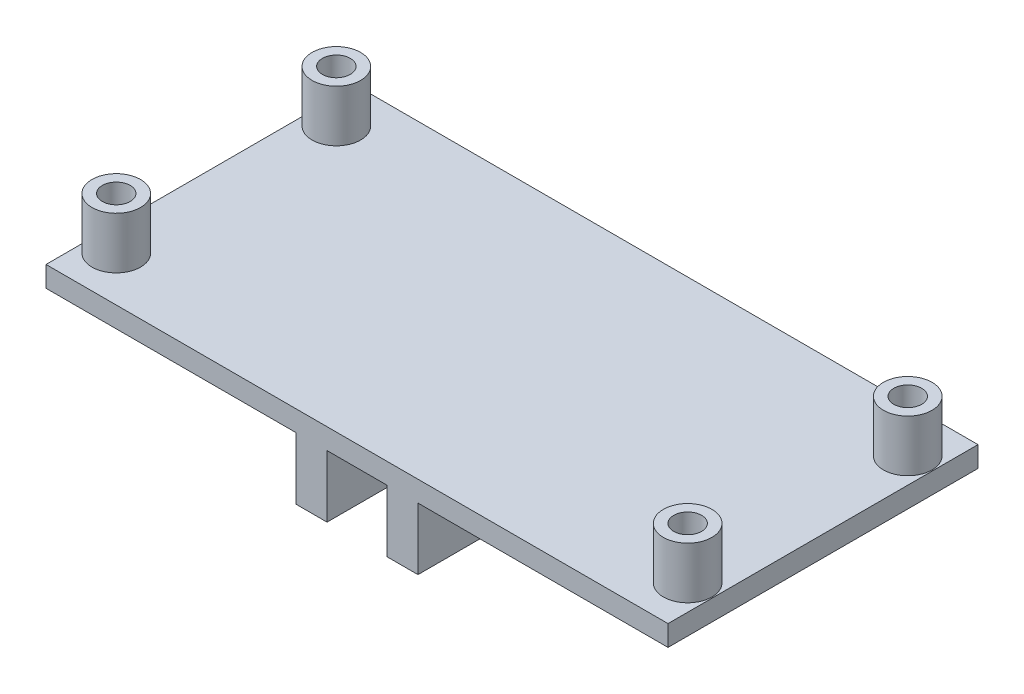
from build123d import *

# Parameters (mm, degrees)
SKETCH_1_W          = 60.2
SKETCH_1_H          = 30
EXTRUDE_1_DEPTH     = 2
SKETCH_2_R          = 1.35
CUT_EXTRUDE_1_DEPTH = 3
SKETCH_3_R          = 2.35
SKETCH_3_R_2        = 1.35
EXTRUDE_2_DEPTH     = 5
SKETCH_4_W          = 3
SKETCH_4_H          = 30
EXTRUDE_3_DEPTH     = 6
SKETCH_5_R          = 1.5
CUT_EXTRUDE_2_DEPTH = 37


with BuildPart() as part:
    # 草图1 → 凸台-拉伸1 (new body)
    with BuildSketch(Plane(origin=(0, 0, 0), x_dir=(1, 0, 0), z_dir=(0, 1, 0))):
        Rectangle(SKETCH_1_W, SKETCH_1_H)
    extrude(amount=EXTRUDE_1_DEPTH)

    # 草图2 → 切除-拉伸1 (cut, through all)
    with BuildSketch(Plane(origin=(0, 2, 0), x_dir=(1, 0, 0), z_dir=(0, 1, 0))):
        with Locations((-27.65, 10.65)):
            Circle(SKETCH_2_R)
        with Locations((-27.65, -10.65)):
            Circle(SKETCH_2_R)
        with Locations((27.65, -10.65)):
            Circle(SKETCH_2_R)
        with Locations((27.65, 10.65)):
            Circle(SKETCH_2_R)
    extrude(amount=-CUT_EXTRUDE_1_DEPTH, mode=Mode.SUBTRACT)

    # 草图3 → 凸台-拉伸2 (add)
    with BuildSketch(Plane(origin=(0, 2, 0), x_dir=(1, 0, 0), z_dir=(0, 1, 0))):
        with Locations((-27.65, 10.65)):
            Circle(SKETCH_3_R)
        with Locations((-27.65, 10.65)):
            Circle(SKETCH_3_R_2, mode=Mode.SUBTRACT)
        with Locations((27.65, 10.65)):
            Circle(SKETCH_3_R)
        with Locations((27.65, 10.65)):
            Circle(SKETCH_3_R_2, mode=Mode.SUBTRACT)
        with Locations((27.65, -10.65)):
            Circle(SKETCH_3_R)
        with Locations((27.65, -10.65)):
            Circle(SKETCH_3_R_2, mode=Mode.SUBTRACT)
        with Locations((-27.65, -10.65)):
            Circle(SKETCH_3_R)
        with Locations((-27.65, -10.65)):
            Circle(SKETCH_3_R_2, mode=Mode.SUBTRACT)
    extrude(amount=EXTRUDE_2_DEPTH)

    # 草图4 → 凸台-拉伸3 (add)
    with BuildSketch(Plane.XZ):
        with Locations((4.4, 0)):
            Rectangle(SKETCH_4_W, SKETCH_4_H)
        with Locations((-4.4, 0)):
            Rectangle(SKETCH_4_W, SKETCH_4_H)
    extrude(amount=EXTRUDE_3_DEPTH)

    # 草图5 → 切除-拉伸2 (cut, through all)
    with BuildSketch(Plane.ZY.offset(5.9)):
        with Locations((-7, -3.75)):
            Circle(SKETCH_5_R)
        with Locations((7.35, -3.75)):
            Circle(SKETCH_5_R)
    extrude(amount=-CUT_EXTRUDE_2_DEPTH, mode=Mode.SUBTRACT)


solid = part.part
